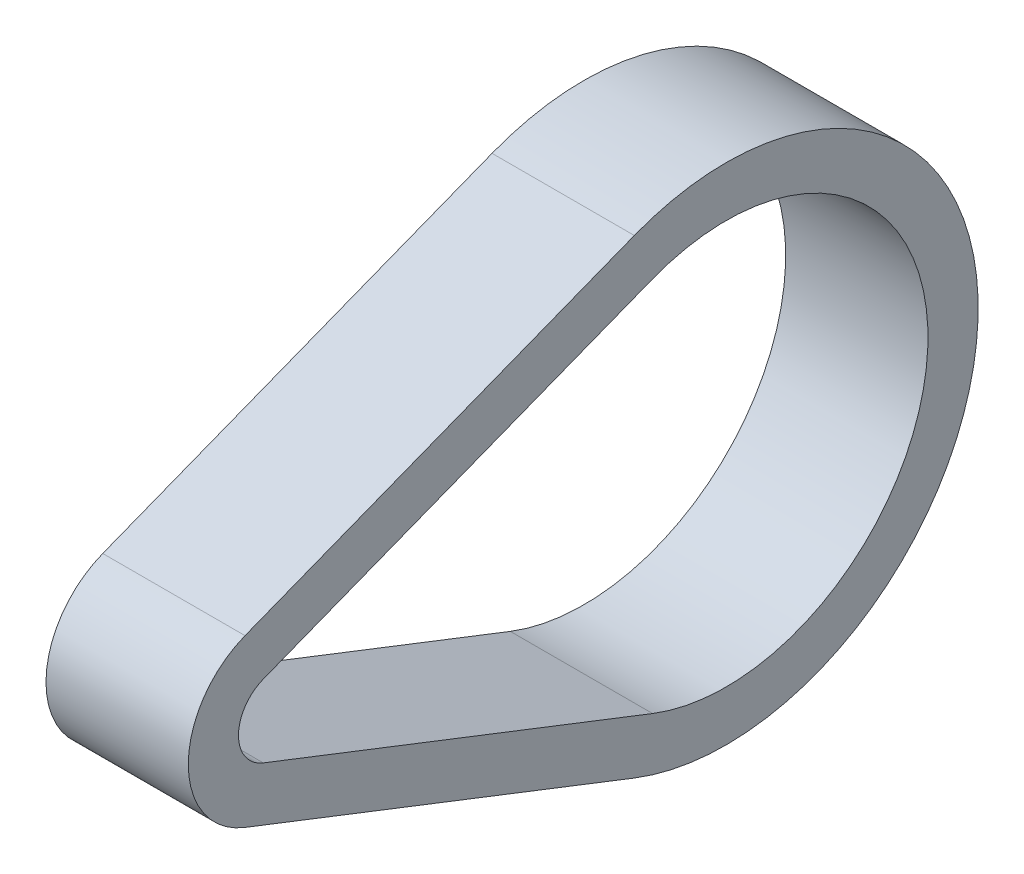
from build123d import *

# Parameters (mm, degrees)
BOSS_EXTRUDE1_DEPTH = 4.5


with BuildPart() as part:
    # Sketch1 → Boss-Extrude1 (new body, symmetric)
    with BuildSketch(Plane(origin=(0, 0, 0), x_dir=(0, 0, -1), z_dir=(1, 0, 0))):
        with BuildLine():
            Line((-2.049554879, 5.25313147), (22.573960072, 14.860209743))
            ThreePointArc((22.573960072, 14.860209743), (44.323, 0), (22.573960072, -14.860209743))
            Line((22.573960072, -14.860209743), (-2.049554879, -5.25313147))
            ThreePointArc((-2.049554879, -5.25313147), (-5.6388, 0), (-2.049554879, 5.25313147))
        make_face()
        with BuildLine():
            Line((-0.895526231, 2.295287174), (23.72798872, 11.902365447))
            ThreePointArc((23.72798872, 11.902365447), (41.148, 0), (23.72798872, -11.902365447))
            Line((23.72798872, -11.902365447), (-0.895526231, -2.295287174))
            ThreePointArc((-0.895526231, -2.295287174), (-2.4638, 0), (-0.895526231, 2.295287174))
        make_face(mode=Mode.SUBTRACT)
    extrude(amount=BOSS_EXTRUDE1_DEPTH, both=True)


solid = part.part
